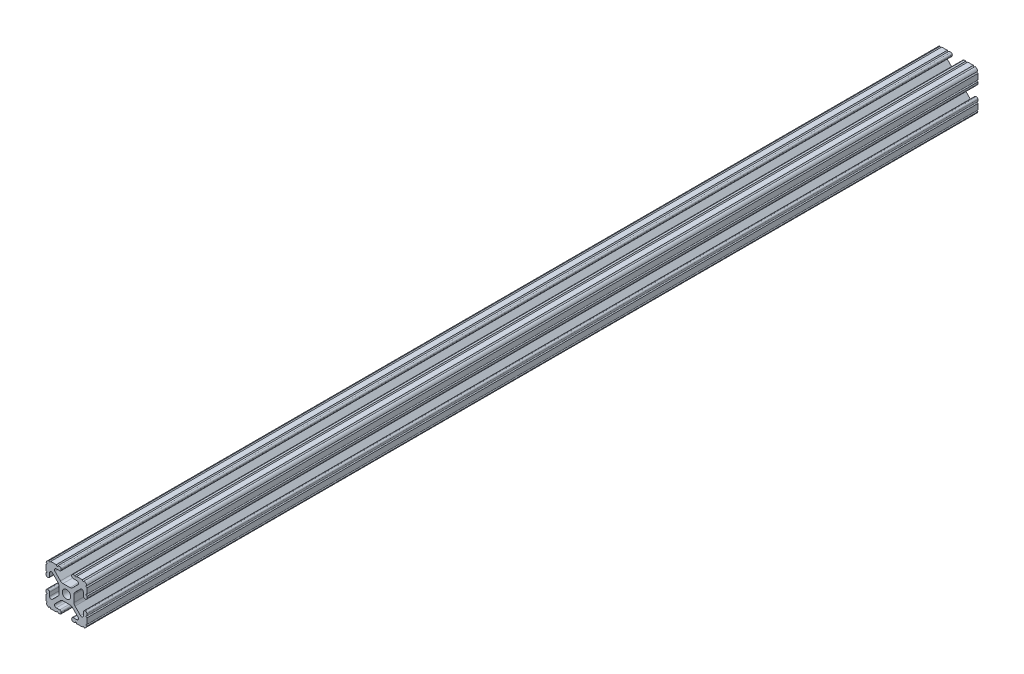
from build123d import *

# Parameters (mm, degrees)
BOSS_EXTRUDE1_DEPTH     = 304.8
SKETCH5_R               = 0.55245
CUT_EXTRUDE1_DEPTH      = 305.8
CUT_EXTRUDE1_DEPTH_BACK = 305.8
SKETCH6_W               = 31.75
SKETCH6_H               = 57.15
CUT_EXTRUDE2_DEPTH      = 12.7


with BuildPart() as part:
    # Sketch4 → Boss-Extrude1 (new body, symmetric)
    with BuildSketch(Plane.XY):
        with BuildLine():
            Line((4.190365, -12.7), (10.11729625, -12.7))
            ThreePointArc((10.11729625, -12.7), (11.943543585, -11.943543585), (12.7, -10.11729625))
            Line((12.7, -10.11729625), (12.7, -4.190365))
            ThreePointArc((12.7, -4.190365), (12.42492494, -3.52627506), (11.760835, -3.2512))
            Line((11.760835, -3.2512), (11.429365, -3.2512))
            ThreePointArc((11.429365, -3.2512), (10.76527506, -3.52627506), (10.4902, -4.190365))
            Line((10.4902, -4.190365), (10.4902, -6.348478019))
            ThreePointArc((10.4902, -6.348478019), (9.830707141, -7.335478831), (8.666460301, -7.103895736))
            Line((8.666460301, -7.103895736), (5.299899128, -3.737334563))
            ThreePointArc((5.299899128, -3.737334563), (4.817571085, -3.015479634), (4.6482, -2.16399369))
            Line((4.6482, -2.16399369), (4.6482, 0))
            Line((4.6482, 0), (2.6035, 0))
            ThreePointArc((2.6035, 0), (1.840952505, -1.840952505), (0, -2.6035))
            Line((0, -2.6035), (0, -4.6482))
            Line((0, -4.6482), (2.16399369, -4.6482))
            ThreePointArc((2.16399369, -4.6482), (3.015479634, -4.817571085), (3.737334563, -5.299899128))
            Line((3.737334563, -5.299899128), (7.103895736, -8.666460301))
            ThreePointArc((7.103895736, -8.666460301), (7.335478831, -9.830707141), (6.348478019, -10.4902))
            Line((6.348478019, -10.4902), (4.190365, -10.4902))
            ThreePointArc((4.190365, -10.4902), (3.52627506, -10.76527506), (3.2512, -11.429365))
            Line((3.2512, -11.429365), (3.2512, -11.760835))
            ThreePointArc((3.2512, -11.760835), (3.52627506, -12.42492494), (4.190365, -12.7))
        make_face()
    extrude(amount=BOSS_EXTRUDE1_DEPTH, both=True)

    # Sketch5 → Cut-Extrude1 (cut, two sides)
    with BuildSketch(Plane.XY) as cut_extrude1_sk:
        with Locations((10.356153152, -12.7)):
            Circle(SKETCH5_R)
        with Locations((5.796028019, -12.7)):
            Circle(SKETCH5_R)
        with Locations((12.7, -10.356153152)):
            Circle(SKETCH5_R)
        with Locations((12.7, -5.796028019)):
            Circle(SKETCH5_R)
    extrude(amount=CUT_EXTRUDE1_DEPTH, mode=Mode.SUBTRACT)
    extrude(cut_extrude1_sk.sketch, amount=-CUT_EXTRUDE1_DEPTH_BACK, mode=Mode.SUBTRACT)

    # Mirror1: part across plane


with BuildPart() as part_1:
    add(part.part)
    add(part.part.mirror(Plane(origin=(0, 0, 0), x_dir=(0, 0, 1), z_dir=(1, 0, 0))))

    # Mirror2: part across plane


with BuildPart() as part_2:
    add(part_1.part)
    add(part_1.part.mirror(Plane.ZX))

    # Sketch6 → Cut-Extrude2 (cut, symmetric)
    with BuildSketch(Plane(origin=(0, 0, 0), x_dir=(1, 0, 0), z_dir=(0, 1, 0))):
        with Locations((-0.060001566, -276.225)):
            Rectangle(SKETCH6_W, SKETCH6_H)
    extrude(amount=CUT_EXTRUDE2_DEPTH, both=True, mode=Mode.SUBTRACT)


solid = part_2.part
